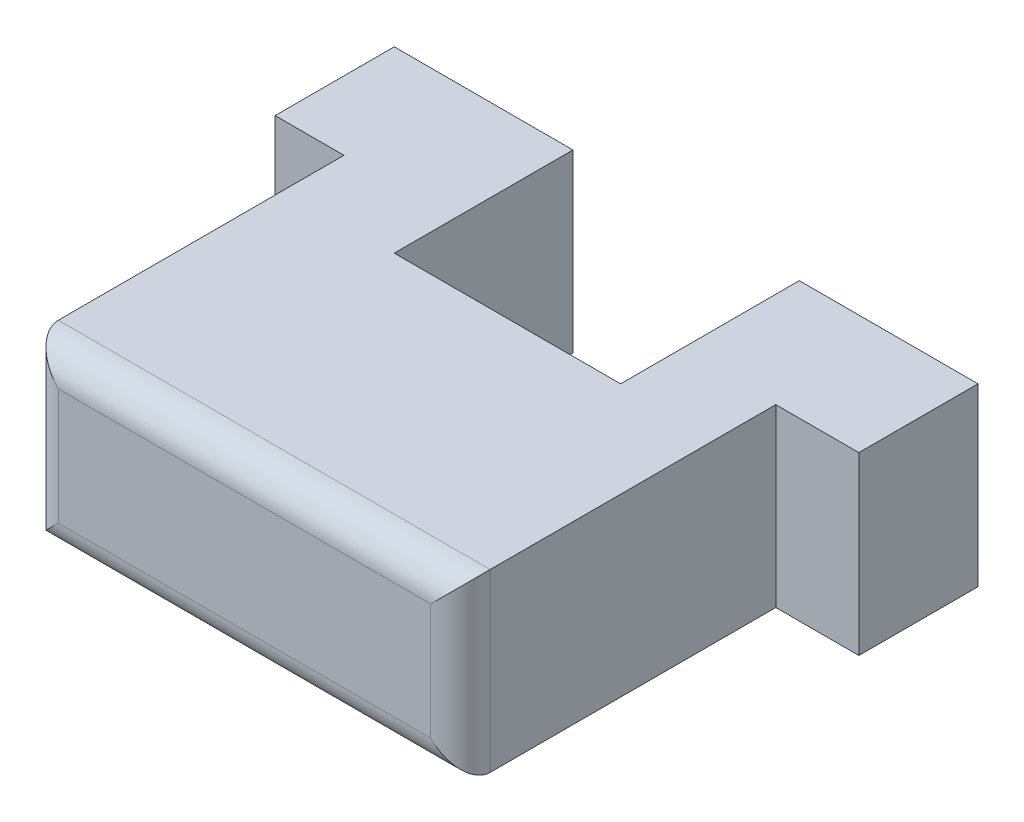
from build123d import *

# Parameters (mm, degrees)
SKETCH1_W           = 14.5
SKETCH1_H           = 5.9
BOSS_EXTRUDE1_DEPTH = 2.59
SKETCH2_W           = 3.689926182
SKETCH2_H           = 5.9
SKETCH2_W_2         = 3.210073818
BOSS_EXTRUDE2_DEPTH = 2
SKETCH5_W           = 6
SKETCH5_H           = 5.9
BOSS_EXTRUDE3_DEPTH = 4
SKETCH7_W           = 14.5
SKETCH7_H           = 5.9
BOSS_EXTRUDE5_DEPTH = 6
FILLET2_R           = 1


with BuildPart() as part:
    # Sketch1 → Boss-Extrude1 (new body)
    with BuildSketch(Plane.XY):
        Rectangle(SKETCH1_W, SKETCH1_H)
    extrude(amount=BOSS_EXTRUDE1_DEPTH)

    # Sketch2 → Boss-Extrude2 (add)
    with BuildSketch(Plane(origin=(0, 0, 0), x_dir=(-1, 0, 0), z_dir=(0, 0, -1))):
        with Locations((5.405036909, 0)):
            Rectangle(SKETCH2_W, SKETCH2_H)
        with Locations((-5.644963091, 0)):
            Rectangle(SKETCH2_W_2, SKETCH2_H)
    extrude(amount=BOSS_EXTRUDE2_DEPTH)

    # Sketch5 → Boss-Extrude3 (add)
    with BuildSketch(Plane(origin=(0, 0, -2), x_dir=(-1, 0, 0), z_dir=(0, 0, -1))):
        with Locations((-7.039926182, 0)):
            Rectangle(SKETCH5_W, SKETCH5_H)
        with Locations((6.560073818, 0)):
            Rectangle(SKETCH5_W, SKETCH5_H)
    extrude(amount=BOSS_EXTRUDE3_DEPTH)

    # Sketch7 → Boss-Extrude5 (add)
    with BuildSketch(Plane.XY.offset(2.59)):
        Rectangle(SKETCH7_W, SKETCH7_H)
    extrude(amount=BOSS_EXTRUDE5_DEPTH)

    # Fillet2
    fillet2_edges = [part.edges().sort_by_distance(p)[0] for p in [
        (0, 2.95, 8.59),
        (-7.25, 0, 8.59),
        (0, -2.95, 8.59),
        (7.25, 0, 8.59),
    ]]
    fillet(fillet2_edges, radius=FILLET2_R)


solid = part.part
